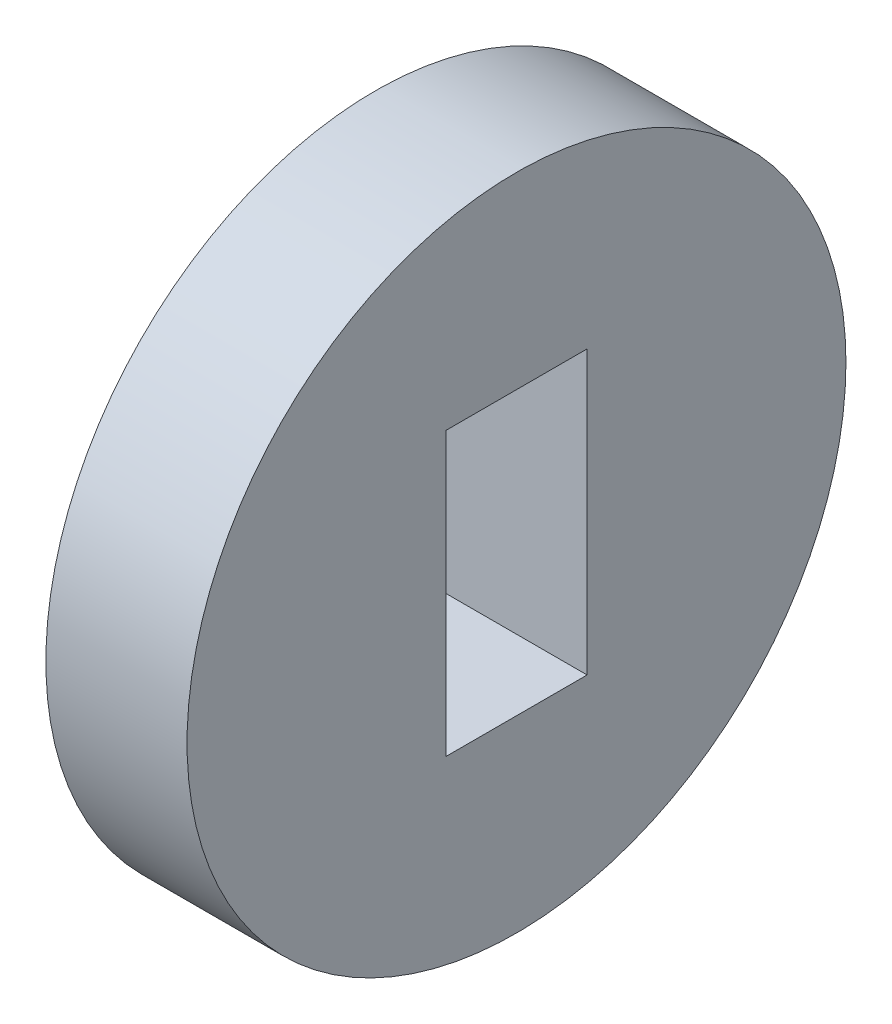
from build123d import *

# Parameters (mm, degrees)
SKETCH1_R           = 7
SKETCH1_W           = 3
SKETCH1_H           = 6
BOSS_EXTRUDE1_DEPTH = 3


with BuildPart() as part:
    # Sketch1 → Boss-Extrude1 (new body)
    with BuildSketch(Plane(origin=(0, 0, 0), x_dir=(0, 0, -1), z_dir=(1, 0, 0))):
        with Locations((-7.268981817, -22.575682471)):
            Circle(SKETCH1_R)
        with Locations((-7.268981817, -22.575682471)):
            Rectangle(SKETCH1_W, SKETCH1_H, mode=Mode.SUBTRACT)
    extrude(amount=BOSS_EXTRUDE1_DEPTH)


solid = part.part
